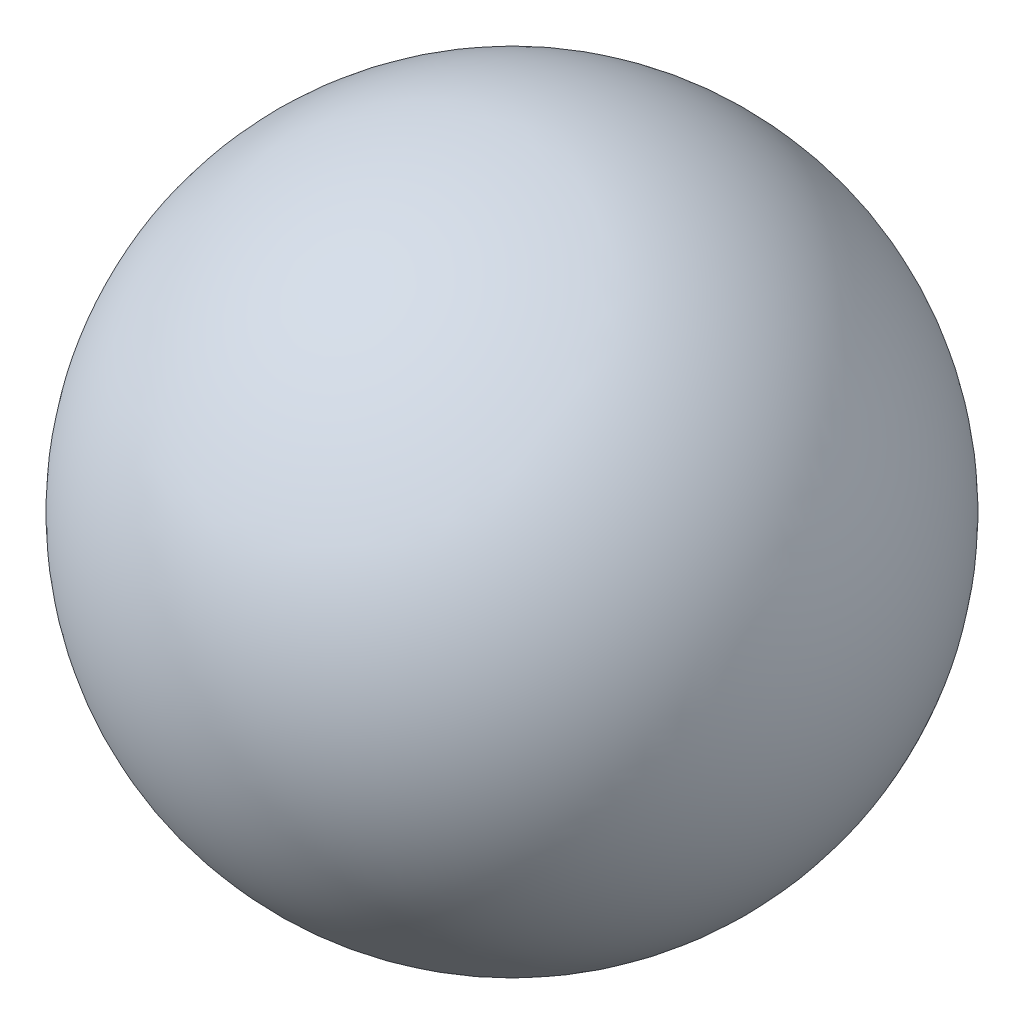
from build123d import *

# Parameters (mm, degrees)
SKETCH2_R          = 12.5
CUT_EXTRUDE1_DEPTH = 31


with BuildPart() as part:
    # Sketch1 → Revolve1 (revolve)
    with BuildSketch(Plane(origin=(0, 0, 0), x_dir=(1, 0, 0), z_dir=(0, 1, 0))):
        with BuildLine():
            Line((0, 30), (0, -30))
            ThreePointArc((0, -30), (30, 0), (0, 30))
        make_face()
    revolve(axis=Axis((0, 0, -30), (0, 0, 1)))

    # Sketch2 → Cut-Extrude1 (cut, through all)
    with BuildSketch(Plane(origin=(0, 0, 0), x_dir=(0, 0, -1), z_dir=(1, 0, 0))):
        Circle(SKETCH2_R)
    extrude(amount=-CUT_EXTRUDE1_DEPTH, mode=Mode.SUBTRACT)


solid = part.part
